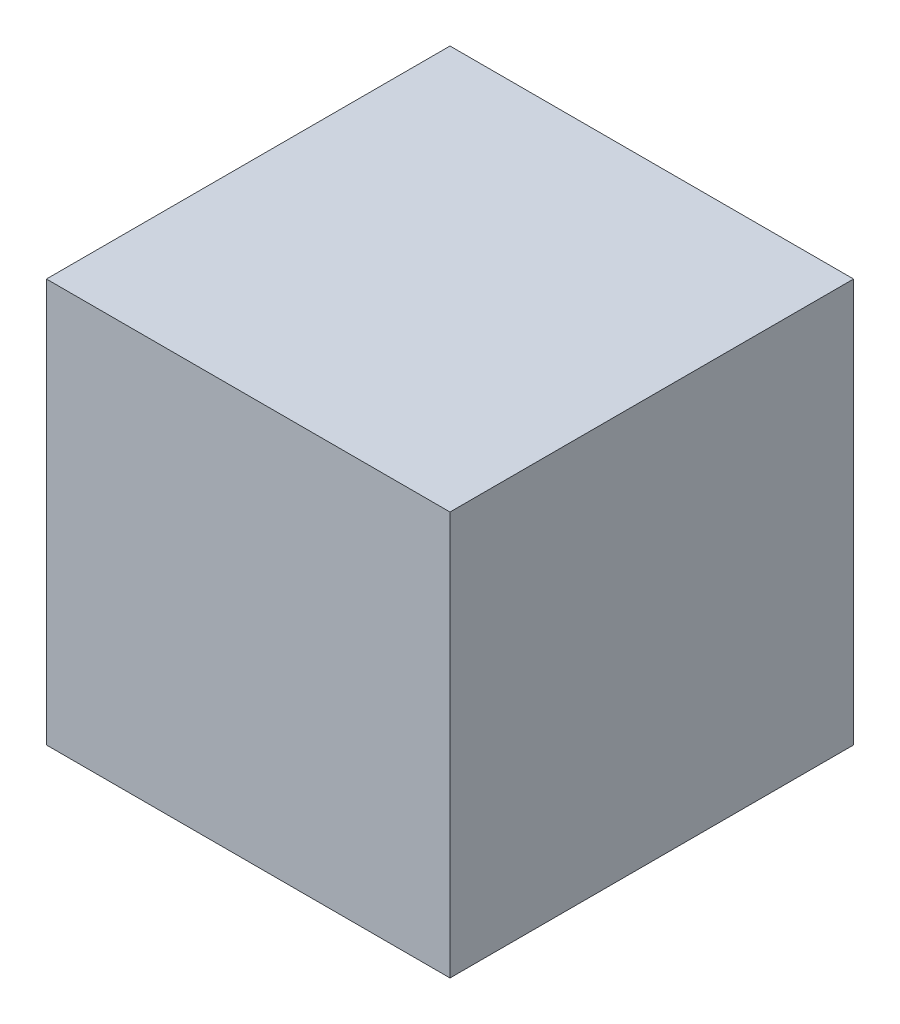
from build123d import *

# Parameters (mm, degrees)
SKETCH_1_W      = 100
SKETCH_1_H      = 100
EXTRUDE_1_DEPTH = 50


with BuildPart() as part:
    # 草图1 → 凸台-拉伸1 (new body, symmetric)
    with BuildSketch(Plane.XY):
        Rectangle(SKETCH_1_W, SKETCH_1_H)
    extrude(amount=EXTRUDE_1_DEPTH, both=True)


solid = part.part
